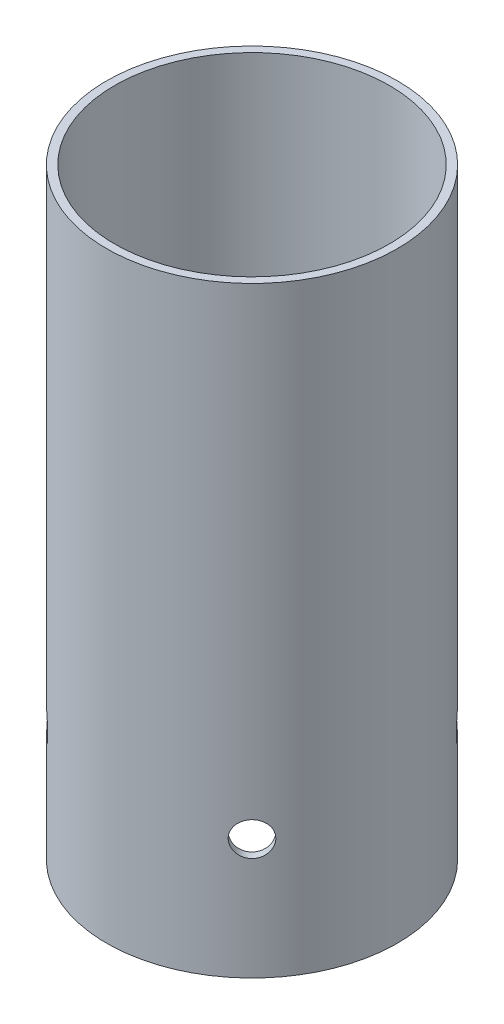
from build123d import *

# Parameters (mm, degrees)
SKETCH1_W          = 0.85
SKETCH1_H          = 63.5
SKETCH2_R          = 1.778
CUT_EXTRUDE1_DEPTH = 2.54
CIRPATTERN1_COUNT  = 4


with BuildPart() as part:
    # Sketch1 → Revolve1 (revolve)
    with BuildSketch(Plane.XY):
        with Locations((-14.925, 285.75)):
            Rectangle(SKETCH1_W, SKETCH1_H)
    revolve(axis=Axis((0, 0, 0), (0, 1, 0)))

    # Sketch2 → Cut-Extrude1 (cut)
    with BuildSketch(Plane(origin=(-10.854089091, 0, 10.854089091), x_dir=(0, -1, 0), z_dir=(-0.707106781, 0, 0.707106781))):
        with Locations((-266.7, 0)):
            Circle(SKETCH2_R)
    cut_extrude1 = extrude(amount=-CUT_EXTRUDE1_DEPTH, mode=Mode.SUBTRACT)

    # CirPattern1: Cut-Extrude1 ×4 about axis
    cirpattern1_axis = Axis((0, 317.5, 0), (0, -1, 0))
    for i in range(1, CIRPATTERN1_COUNT):
        add(cut_extrude1.rotate(cirpattern1_axis, i * 360 / CIRPATTERN1_COUNT), mode=Mode.SUBTRACT)


solid = part.part
